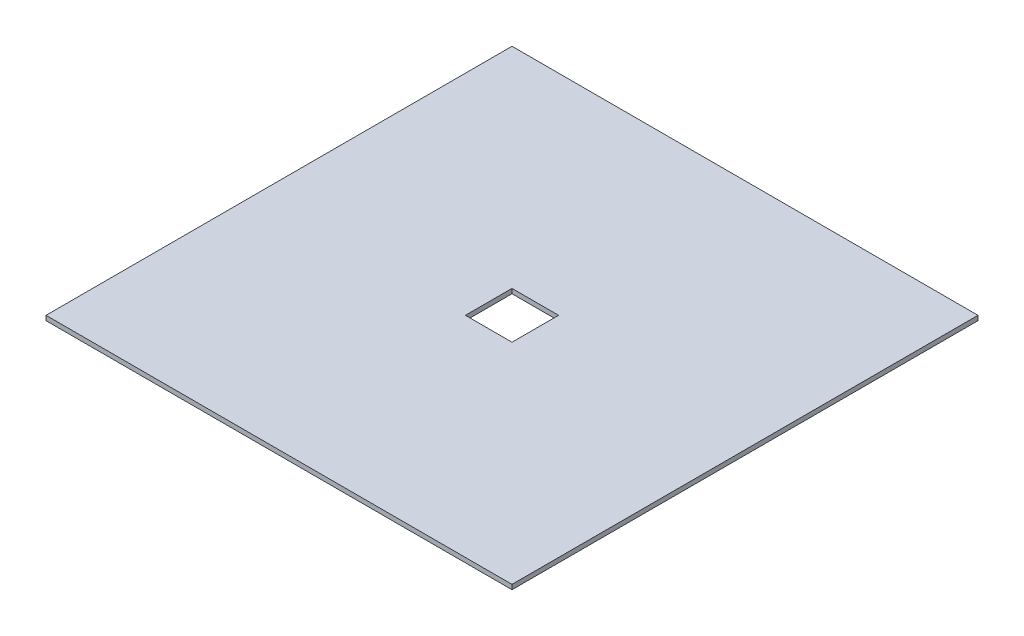
from build123d import *

# Parameters (mm, degrees)
SKETCH2_W               = 500
SKETCH2_H               = 500
BOSS_EXTRUDE1_DEPTH     = 5
CUT_EXTRUDE5_DEPTH      = 5
CUT_EXTRUDE5_DEPTH_BACK = 5
SKETCH3_W               = 50
SKETCH3_H               = 50


with BuildPart() as part:
    # Sketch2 → Boss-Extrude1 (new body)
    with BuildSketch(Plane(origin=(0, 0, 0), x_dir=(1, 0, 0), z_dir=(0, 1, 0))):
        Rectangle(SKETCH2_W, SKETCH2_H)
    extrude(amount=BOSS_EXTRUDE1_DEPTH)

    # Sketch3 → Cut-Extrude5 (cut, two sides: drawn at the far end of the back side and taken through both)
    with BuildSketch(Plane(origin=(0, 0, 0), x_dir=(1, 0, 0), z_dir=(0, 1, 0)).offset(-CUT_EXTRUDE5_DEPTH_BACK)):
        Rectangle(SKETCH3_W, SKETCH3_H)
    extrude(amount=CUT_EXTRUDE5_DEPTH + CUT_EXTRUDE5_DEPTH_BACK, mode=Mode.SUBTRACT)


solid = part.part
